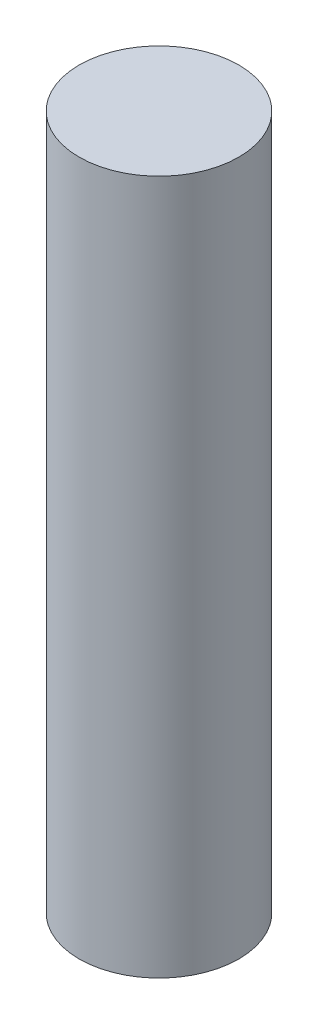
from build123d import *

# Parameters (mm, degrees)
SKETCH1_R           = 5
BOSS_EXTRUDE1_DEPTH = 43.5


with BuildPart() as part:
    # Sketch1 → Boss-Extrude1 (new body)
    with BuildSketch(Plane(origin=(0, 0, 0), x_dir=(1, 0, 0), z_dir=(0, 1, 0))):
        Circle(SKETCH1_R)
    extrude(amount=BOSS_EXTRUDE1_DEPTH)


solid = part.part
